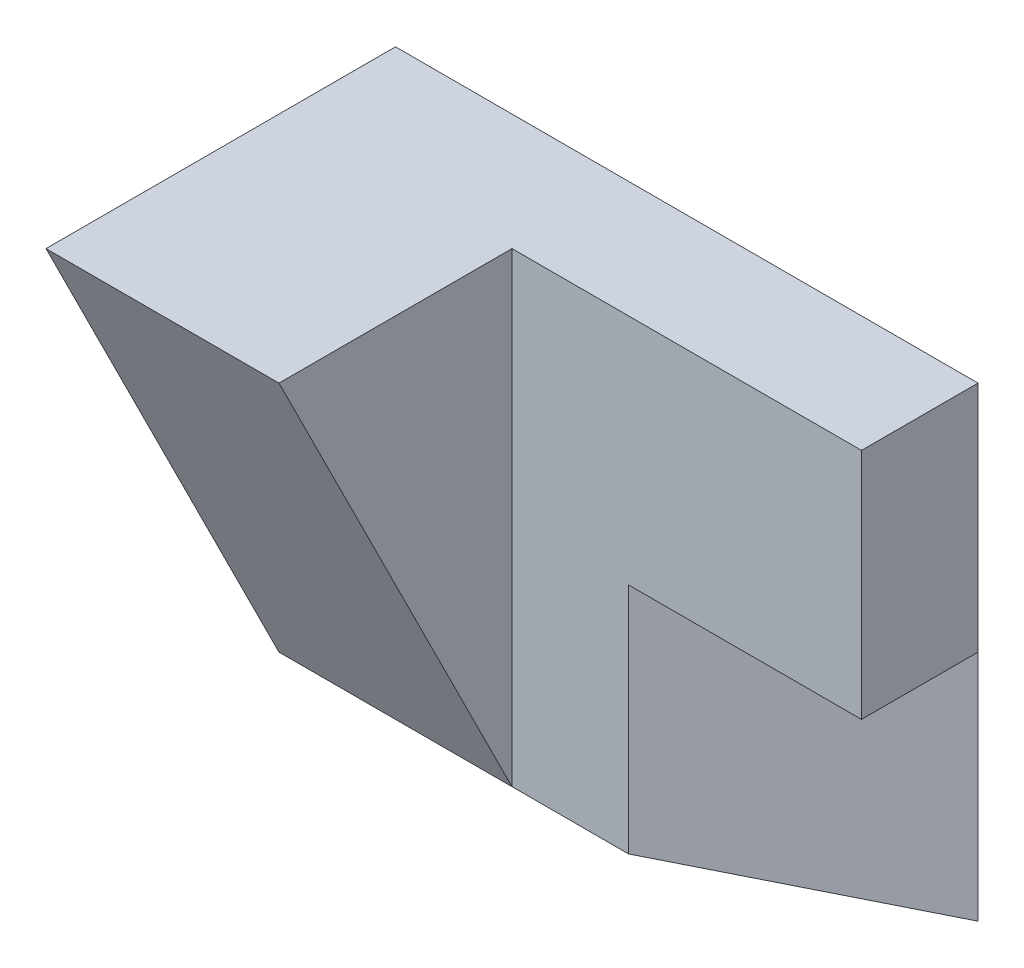
from build123d import *

# Parameters (mm, degrees)
SKETCH1_W           = 50
SKETCH1_H           = 40
BOSS_EXTRUDE1_DEPTH = 10
CUT_EXTRUDE1_DEPTH  = 20
SKETCH4_W           = 20
SKETCH4_H           = 40
BOSS_EXTRUDE3_DEPTH = 20
CUT_EXTRUDE3_DEPTH  = 20


with BuildPart() as part:
    # Sketch1 → Boss-Extrude1 (new body)
    with BuildSketch(Plane.XY):
        with Locations((25, 20)):
            Rectangle(SKETCH1_W, SKETCH1_H)
    extrude(amount=BOSS_EXTRUDE1_DEPTH)

    # Sketch3 → Cut-Extrude1 (cut)
    with BuildSketch(Plane.XZ):
        Polygon((30, 10), (50, 0), (50, 10), align=None)
    extrude(amount=-CUT_EXTRUDE1_DEPTH, mode=Mode.SUBTRACT)

    # Sketch4 → Boss-Extrude3 (add)
    with BuildSketch(Plane.XY.offset(10)):
        with Locations((10, 20)):
            Rectangle(SKETCH4_W, SKETCH4_H)
    extrude(amount=BOSS_EXTRUDE3_DEPTH)

    # Sketch7 → Cut-Extrude3 (cut)
    with BuildSketch(Plane.ZY):
        Polygon((30, 40), (10, 0), (30, 0), align=None)
    extrude(amount=-CUT_EXTRUDE3_DEPTH, mode=Mode.SUBTRACT)


solid = part.part
